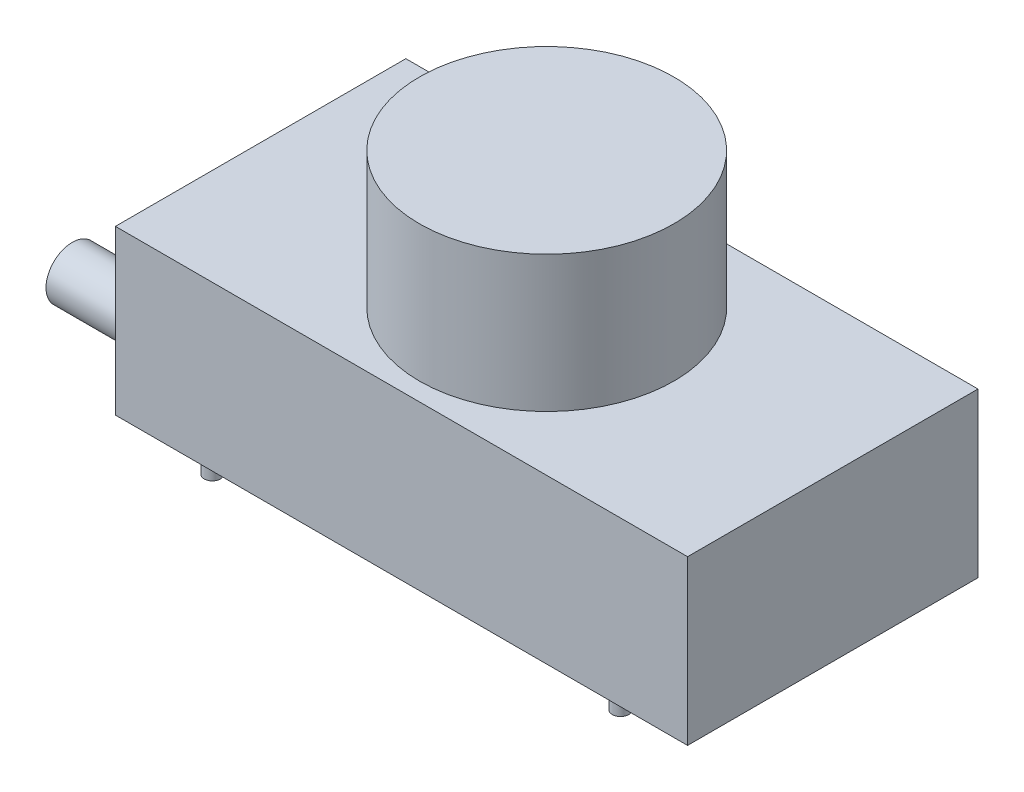
from build123d import *

# Parameters (mm, degrees)
SKETCH1_W           = 105
SKETCH1_H           = 53.3
BOSS_EXTRUDE1_DEPTH = 30
SKETCH2_R           = 4.818720667
SKETCH2_W           = 7.589906064
SKETCH2_H           = 7.253051844
BOSS_EXTRUDE2_DEPTH = 20
SKETCH3_R           = 23.34946898
BOSS_EXTRUDE3_DEPTH = 25
SKETCH4_R           = 1.5
BOSS_EXTRUDE4_DEPTH = 3


with BuildPart() as part:
    # Sketch1 → Boss-Extrude1 (new body)
    with BuildSketch(Plane(origin=(0, 0, 0), x_dir=(1, 0, 0), z_dir=(0, 1, 0))):
        Rectangle(SKETCH1_W, SKETCH1_H)
    extrude(amount=BOSS_EXTRUDE1_DEPTH)

    # Sketch2 → Boss-Extrude2 (add)
    with BuildSketch(Plane.ZY.offset(52.5)):
        with Locations((14.56750928, 6.602710937)):
            Circle(SKETCH2_R)
        with Locations((-17.806950585, 5.197359545)):
            Rectangle(SKETCH2_W, SKETCH2_H)
    extrude(amount=BOSS_EXTRUDE2_DEPTH)

    # Sketch3 → Boss-Extrude3 (add)
    with BuildSketch(Plane(origin=(0, 30, 0), x_dir=(1, 0, 0), z_dir=(0, 1, 0))):
        Circle(SKETCH3_R)
    extrude(amount=BOSS_EXTRUDE3_DEPTH)

    # Sketch4 → Boss-Extrude4 (add)
    with BuildSketch(Plane.XZ):
        with Locations((-37.2, 24.15)):
            Circle(SKETCH4_R)
        with Locations((-38.5, -24.15)):
            Circle(SKETCH4_R)
        with Locations((37.7, 24.15)):
            Circle(SKETCH4_R)
        with Locations((43.6, -24.15)):
            Circle(SKETCH4_R)
    extrude(amount=BOSS_EXTRUDE4_DEPTH)


solid = part.part
